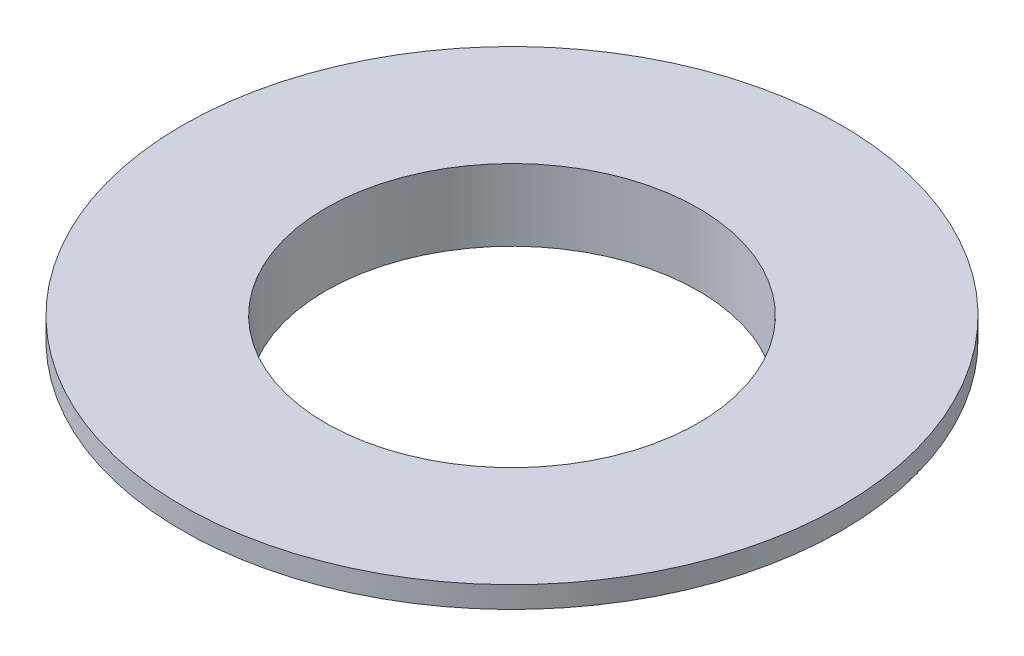
from build123d import *


with BuildPart() as part:
    # Sketch1 → Revolve1 (revolve)
    with BuildSketch(Plane.XY):
        Polygon((0, 0), (0, 10), (20, 10), (20, 7), (4, 7), (4, 0), align=None)
    revolve(axis=Axis((-26, 37.868979058, 0), (0, -1, 0)))


solid = part.part
